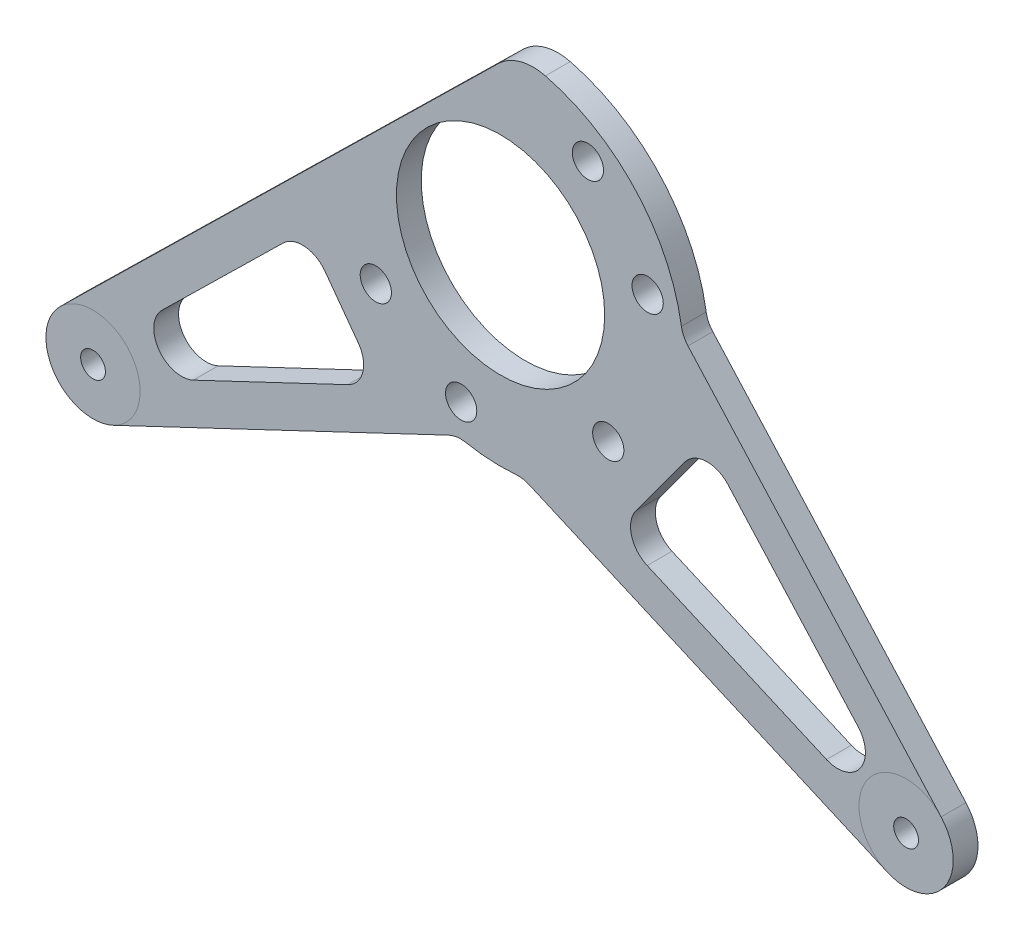
from build123d import *

# Parameters (mm, degrees)
SKETCH4_R           = 26.67
SKETCH4_R_2         = 3.175
SKETCH4_R_3         = 4
BOSS_EXTRUDE1_DEPTH = 6.35


with BuildPart() as part:
    # Sketch4 → Boss-Extrude1 (new body)
    with BuildSketch(Plane.XY):
        with BuildLine():
            Line((-112.821947343, -67.861519054), (-0.515655425, 42.221127865))
            ThreePointArc((-0.515655425, 42.221127865), (5.060574998, 45.411581565), (11.484788098, 45.464747253))
            ThreePointArc((11.484788098, 45.464747253), (34.621914338, 31.626992395), (46.315565637, 7.335664942))
            ThreePointArc((46.315565637, 7.335664942), (46.8988099, 5.456870428), (47.991424982, 3.820950204))
            Line((47.991424982, 3.820950204), (112.830192448, -68.228316343))
            ThreePointArc((112.830192448, -68.228316343), (113.646801884, -83.357459106), (99.032580967, -87.355253332))
            Line((99.032580967, -87.355253332), (7.333742713, -47.300802353))
            ThreePointArc((7.333742713, -47.300802353), (5.650340933, -46.801981002), (3.896034016, -46.730766304))
            ThreePointArc((3.896034016, -46.730766304), (-2.51262623, -46.825530534), (-8.874346459, -46.045516343))
            ThreePointArc((-8.874346459, -46.045516343), (-11.116219354, -45.973658852), (-13.268973959, -46.603583598))
            Line((-13.268973959, -46.603583598), (-99.204524399, -87.377892758))
            ThreePointArc((-99.204524399, -87.377892758), (-114.270940187, -83.381465438), (-112.821947343, -67.861519054))
        make_face()
        Circle(SKETCH4_R, mode=Mode.SUBTRACT)
        with Locations((103.862003689, -76.298992609)):
            Circle(SKETCH4_R_2, mode=Mode.SUBTRACT)
        with Locations((-104.376429258, -76.477634727)):
            Circle(SKETCH4_R_2, mode=Mode.SUBTRACT)
        with Locations((-10.093942759, -37.671107225)):
            Circle(SKETCH4_R_3, mode=Mode.SUBTRACT)
        with Locations((-31.946929727, -22.369481018)):
            Circle(SKETCH4_R_3, mode=Mode.SUBTRACT)
        with Locations((27.577164466, -27.577164466)):
            Circle(SKETCH4_R_3, mode=Mode.SUBTRACT)
        with Locations((37.671107225, 10.093942759)):
            Circle(SKETCH4_R_3, mode=Mode.SUBTRACT)
        with Locations((22.369481018, 31.946929727)):
            Circle(SKETCH4_R_3, mode=Mode.SUBTRACT)
        with BuildLine():
            Line((-86.689084945, -55.583778017), (-55.691219904, -25.199665298))
            ThreePointArc((-55.691219904, -25.199665298), (-50.133633158, -23.190261002), (-44.975951587, -26.075186805))
            Line((-44.975951587, -26.075186805), (-36.452805068, -37.70754969))
            ThreePointArc((-36.452805068, -37.70754969), (-35.294757483, -43.654797982), (-39.140960913, -48.336416892))
            Line((-39.140960913, -48.336416892), (-78.661972473, -67.088166726))
            ThreePointArc((-78.661972473, -67.088166726), (-87.543228095, -64.73237799), (-86.689084945, -55.583778017))
        make_face(mode=Mode.SUBTRACT)
        with BuildLine():
            Line((34.66659199, -39.378036032), (47.195108172, -22.323593379))
            ThreePointArc((47.195108172, -22.323593379), (52.574176498, -19.430906367), (58.213255891, -21.776710666))
            Line((58.213255891, -21.776710666), (91.616099201, -58.894170716))
            ThreePointArc((91.616099201, -58.894170716), (92.097468974, -67.812402239), (83.482770328, -70.16899673))
            Line((83.482770328, -70.16899673), (37.551410836, -50.105979333))
            ThreePointArc((37.551410836, -50.105979333), (33.530211234, -45.435462365), (34.66659199, -39.378036032))
        make_face(mode=Mode.SUBTRACT)
    extrude(amount=BOSS_EXTRUDE1_DEPTH)


solid = part.part
